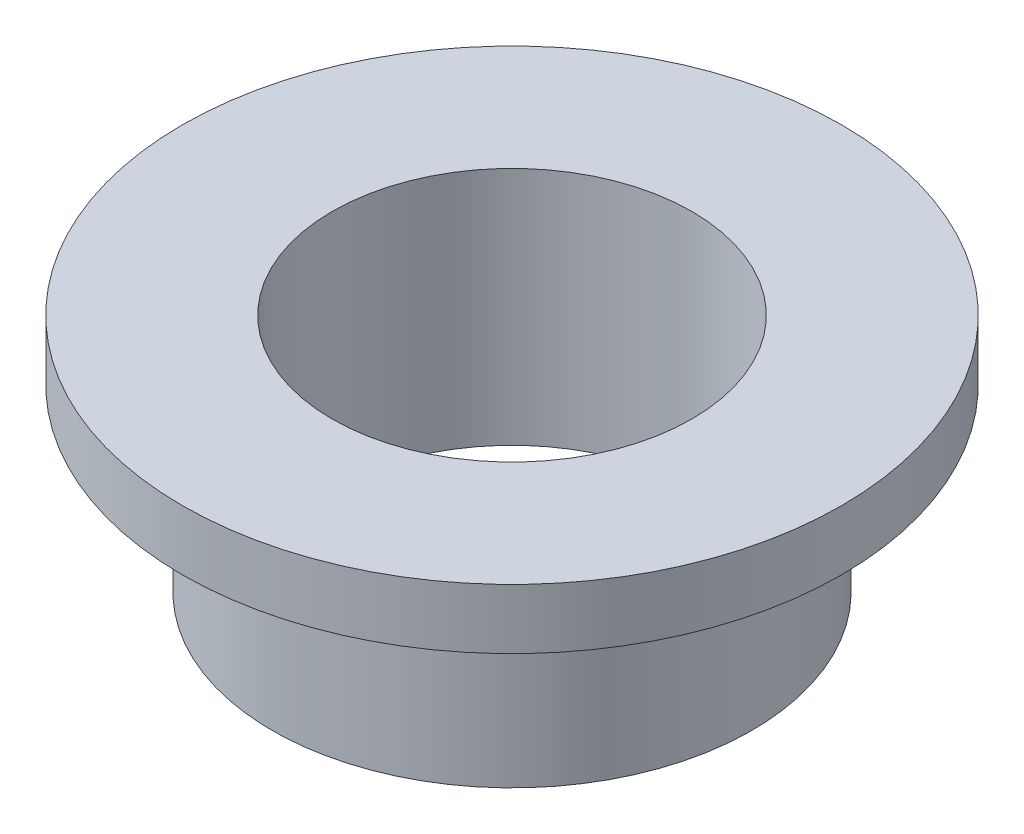
from build123d import *


with BuildPart() as part:
    # Sketch1 → Revolve1 (revolve)
    with BuildSketch(Plane.XY):
        Polygon((4.7625, -11.638350357), (8.73125, -11.638350357), (8.73125, -13.225850357), (6.35, -13.225850357), (6.35, -17.988350357), (4.7625, -17.988350357), align=None)
    revolve(axis=Axis((0, -55, 0), (0, 1, 0)))


solid = part.part
